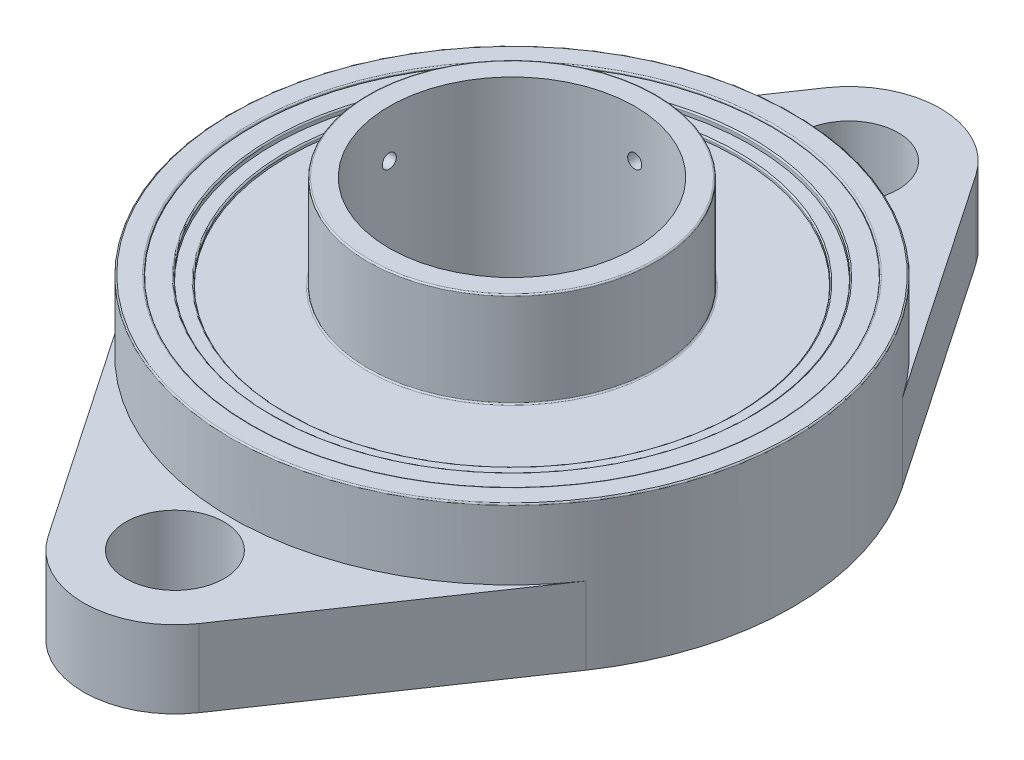
from build123d import *

# Parameters (mm, degrees)
SKETCH1_R             = 7
SKETCH1_R_2           = 37
EXTRUDE_A1_DEPTH      = 11
SKETCH1_3_R           = 37
EXTRUDE_A_DEPTH       = 21
SKETCH1_4_R           = 20.5
SKETCH1_4_R_2         = 17.5
EXTRUDE_A0_DEPTH      = 33
BEARING_START         = 2
SKETCH1_7_R           = 34
SKETCH1_7_R_2         = 32
BEARING_OUTER_D_DEPTH = 18
BOSS_EXTRUDE6_START   = 1.2
SKETCH1_8_R           = 37
SKETCH1_8_R_2         = 34
BOSS_EXTRUDE6_DEPTH   = 19.5
BOSS_EXTRUDE7_START   = 1.5
SKETCH1_9_R           = 32
SKETCH1_9_R_2         = 20.5
BOSS_EXTRUDE7_DEPTH   = 18
CUT_EXTRUDE1_REACH    = 82.062
SKETCH2_R             = 1
CUT_EXTRUDE2_REACH    = 82.062
SKETCH3_R             = 1
FILLET1_R             = 0.2
FILLET2_R             = 0.2


with BuildPart() as part:
    # Sketch1 → Extrude A1 (new body)
    with BuildSketch(Plane(origin=(0, 0, 0), x_dir=(1, 0, 0), z_dir=(0, 1, 0))):
        with BuildLine():
            Line((10.748364701, -55.3125), (33.071891388, -22.5))
            ThreePointArc((33.071891388, -22.5), (40, 0), (33.071891388, 22.5))
            Line((33.071891388, 22.5), (10.748364701, 55.3125))
            ThreePointArc((10.748364701, 55.3125), (0, 61), (-10.748364701, 55.3125))
            Line((-10.748364701, 55.3125), (-33.071891388, 22.5))
            ThreePointArc((-33.071891388, 22.5), (-40, 0), (-33.071891388, -22.5))
            Line((-33.071891388, -22.5), (-10.748364701, -55.3125))
            ThreePointArc((-10.748364701, -55.3125), (0, -61), (10.748364701, -55.3125))
        make_face()
        with Locations((0, -48)):
            Circle(SKETCH1_R, mode=Mode.SUBTRACT)
        Circle(SKETCH1_R_2, mode=Mode.SUBTRACT)
        with Locations((0, 48)):
            Circle(SKETCH1_R, mode=Mode.SUBTRACT)
    extrude(amount=EXTRUDE_A1_DEPTH)

    # Sketch1_3 → Extrude A (add)
    with BuildSketch(Plane(origin=(0, 0, 0), x_dir=(1, 0, 0), z_dir=(0, 1, 0))):
        with BuildLine():
            ThreePointArc((-33.071891388, -22.5), (0, -40), (33.071891388, -22.5))
            ThreePointArc((33.071891388, -22.5), (38.228756555, -11.771243445), (40, 0))
            ThreePointArc((40, 0), (38.228756555, 11.771243445), (33.071891388, 22.5))
            ThreePointArc((33.071891388, 22.5), (0, 40), (-33.071891388, 22.5))
            ThreePointArc((-33.071891388, 22.5), (-40, 0), (-33.071891388, -22.5))
        make_face()
        Circle(SKETCH1_3_R, mode=Mode.SUBTRACT)
    extrude(amount=EXTRUDE_A_DEPTH)



with BuildPart() as body_2:
    # Sketch1_4 → Extrude A0 (new body)
    with BuildSketch(Plane(origin=(0, 0, 0), x_dir=(1, 0, 0), z_dir=(0, 1, 0))):
        Circle(SKETCH1_4_R)
        Circle(SKETCH1_4_R_2, mode=Mode.SUBTRACT)
    extrude(amount=EXTRUDE_A0_DEPTH)


with BuildPart() as body_3:
    # Sketch1_7 → Bearing outer d (new body)
    with BuildSketch(Plane(origin=(0, 0, 0), x_dir=(1, 0, 0), z_dir=(0, 1, 0)).offset(BEARING_START)):
        Circle(SKETCH1_7_R)
        Circle(SKETCH1_7_R_2, mode=Mode.SUBTRACT)
    extrude(amount=BEARING_OUTER_D_DEPTH)


with BuildPart() as part_1:
    add(part.part)

    add(body_3.part)  # Boss-Extrude6 merges body 3
    # Sketch1_8 → Boss-Extrude6 (add)
    with BuildSketch(Plane(origin=(0, 0, 0), x_dir=(1, 0, 0), z_dir=(0, 1, 0)).offset(BOSS_EXTRUDE6_START)):
        Circle(SKETCH1_8_R)
        Circle(SKETCH1_8_R_2, mode=Mode.SUBTRACT)
    extrude(amount=BOSS_EXTRUDE6_DEPTH)


    add(body_2.part)  # Boss-Extrude7 merges body 2
    # Sketch1_9 → Boss-Extrude7 (add)
    with BuildSketch(Plane(origin=(0, 0, 0), x_dir=(1, 0, 0), z_dir=(0, 1, 0)).offset(BOSS_EXTRUDE7_START)):
        Circle(SKETCH1_9_R)
        Circle(SKETCH1_9_R_2, mode=Mode.SUBTRACT)
    extrude(amount=BOSS_EXTRUDE7_DEPTH)

    # Sketch2 → Cut-Extrude1 (cut, up to next)
    with BuildSketch(Plane(origin=(0, 0, 0), x_dir=(0, 0, -1), z_dir=(1, 0, 0)), mode=Mode.PRIVATE) as cut_extrude1_sk1:
        with Locations((0, 26.25)):
            Circle(SKETCH2_R)
    cut_extrude1_tool1 = extrude(cut_extrude1_sk1.sketch, amount=-CUT_EXTRUDE1_REACH, mode=Mode.PRIVATE) & part_1.part
    add(cut_extrude1_tool1.solids().sort_by_distance((0, 26.25, 0))[0], mode=Mode.SUBTRACT)

    # Sketch3 → Cut-Extrude2 (cut, up to next)
    with BuildSketch(Plane.XY, mode=Mode.PRIVATE) as cut_extrude2_sk1:
        with Locations((0, 26.25)):
            Circle(SKETCH3_R)
    cut_extrude2_tool1 = extrude(cut_extrude2_sk1.sketch, amount=-CUT_EXTRUDE2_REACH, mode=Mode.PRIVATE) & part_1.part
    add(cut_extrude2_tool1.solids().sort_by_distance((0, 26.25, 0))[0], mode=Mode.SUBTRACT)

    # Fillet1
    fillet1_edges = [part_1.edges().sort_by_distance(p)[0] for p in [
        (-32, 20, 0),
    ]]
    fillet(fillet1_edges, radius=FILLET1_R)

    # Fillet2
    fillet2_edges = [part_1.edges().sort_by_distance(p)[0] for p in [
        (-20.5, 33, 0),
        (-20.5, 19.5, 0),
        (33.071891388, 21, -22.5),
        (-37, 21, 0),
        (-34, 20.7, 0),
    ]]
    fillet(fillet2_edges, radius=FILLET2_R)


solid = part_1.part
